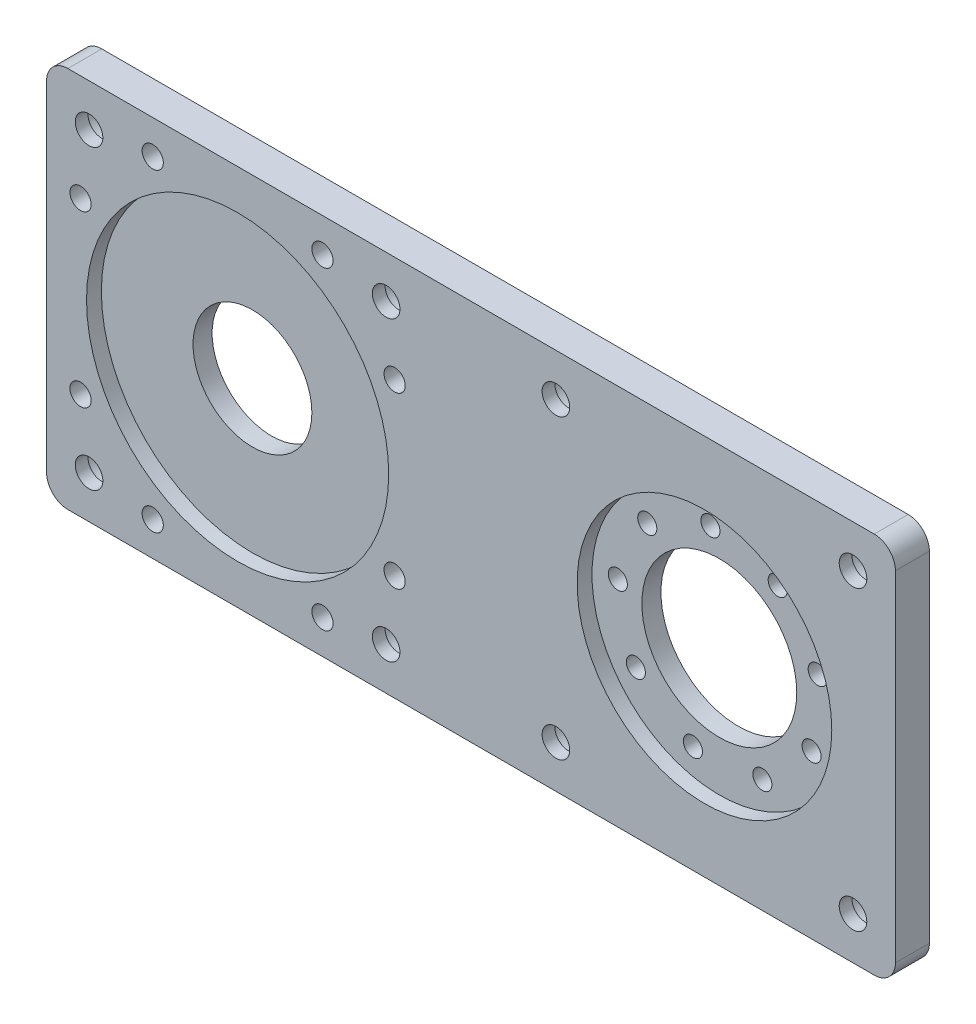
from build123d import *

# Parameters (mm, degrees)
SKETCH1_W           = 200
SKETCH1_H           = 90
SKETCH1_R           = 14
SKETCH1_R_2         = 18.25
SKETCH1_R_3         = 2.25
SKETCH1_R_4         = 3.25
SKETCH1_R_5         = 2.5
BOSS_EXTRUDE1_DEPTH = 4
FILLET1_R           = 5
SKETCH3_R           = 35.6
SKETCH3_R_2         = 30
CUT_EXTRUDE1_DEPTH  = 3.5
SKETCH4_R           = 5
CUT_EXTRUDE2_DEPTH  = 5


with BuildPart() as part:
    # Sketch1 → Boss-Extrude1 (new body, symmetric)
    with BuildSketch(Plane.XY):
        Rectangle(SKETCH1_W, SKETCH1_H)
        with Locations((-55, 0)):
            Circle(SKETCH1_R, mode=Mode.SUBTRACT)
        with Locations((55, 0)):
            Circle(SKETCH1_R_2, mode=Mode.SUBTRACT)
        with Locations((65.142838282, -21.751386889)):
            Circle(SKETCH1_R_3, mode=Mode.SUBTRACT)
        with Locations((48.788342918, -23.182219831)):
            Circle(SKETCH1_R_3, mode=Mode.SUBTRACT)
        with Locations((35.340350937, -13.765834472)):
            Circle(SKETCH1_R_3, mode=Mode.SUBTRACT)
        with Locations((31.091327246, 2.091737826)):
            Circle(SKETCH1_R_3, mode=Mode.SUBTRACT)
        with Locations((38.029437252, 16.970562748)):
            Circle(SKETCH1_R_3, mode=Mode.SUBTRACT)
        with Locations((52.908262174, 23.908672754)):
            Circle(SKETCH1_R_3, mode=Mode.SUBTRACT)
        with Locations((68.765834472, 19.659649063)):
            Circle(SKETCH1_R_3, mode=Mode.SUBTRACT)
        with Locations((78.182219831, 6.211657082)):
            Circle(SKETCH1_R_3, mode=Mode.SUBTRACT)
        with Locations((76.751386889, -10.142838282)):
            Circle(SKETCH1_R_3, mode=Mode.SUBTRACT)
        with Locations((-90, 35)):
            Circle(SKETCH1_R_4, mode=Mode.SUBTRACT)
        with Locations((-20, 35)):
            Circle(SKETCH1_R_4, mode=Mode.SUBTRACT)
        with Locations((-90, -35)):
            Circle(SKETCH1_R_4, mode=Mode.SUBTRACT)
        with Locations((-20, -35)):
            Circle(SKETCH1_R_4, mode=Mode.SUBTRACT)
        with Locations((90, 35)):
            Circle(SKETCH1_R_4, mode=Mode.SUBTRACT)
        with Locations((90, -35)):
            Circle(SKETCH1_R_4, mode=Mode.SUBTRACT)
        with Locations((20, -35)):
            Circle(SKETCH1_R_4, mode=Mode.SUBTRACT)
        with Locations((20, 35)):
            Circle(SKETCH1_R_4, mode=Mode.SUBTRACT)
        with Locations((-75, 37)):
            Circle(SKETCH1_R_5, mode=Mode.SUBTRACT)
        with Locations((-92, 20)):
            Circle(SKETCH1_R_5, mode=Mode.SUBTRACT)
        with Locations((-92, -20)):
            Circle(SKETCH1_R_5, mode=Mode.SUBTRACT)
        with Locations((-75, -37)):
            Circle(SKETCH1_R_5, mode=Mode.SUBTRACT)
        with Locations((-35, -37)):
            Circle(SKETCH1_R_5, mode=Mode.SUBTRACT)
        with Locations((-18, -20)):
            Circle(SKETCH1_R_5, mode=Mode.SUBTRACT)
        with Locations((-18, 20)):
            Circle(SKETCH1_R_5, mode=Mode.SUBTRACT)
        with Locations((-35, 37)):
            Circle(SKETCH1_R_5, mode=Mode.SUBTRACT)
    extrude(amount=BOSS_EXTRUDE1_DEPTH, both=True)

    # Fillet1
    fillet1_edges = [part.edges().sort_by_distance(p)[0] for p in [
        (100, -45, 0),
        (-100, -45, 0),
        (-100, 45, 0),
        (100, 45, 0),
    ]]
    fillet(fillet1_edges, radius=FILLET1_R)

    # Sketch3 → Cut-Extrude1 (cut)
    with BuildSketch(Plane.XY.offset(4)):
        with Locations((-55, 0)):
            Circle(SKETCH3_R)
        with Locations((55, 0)):
            Circle(SKETCH3_R_2)
    extrude(amount=-CUT_EXTRUDE1_DEPTH, mode=Mode.SUBTRACT)

    # Sketch4 → Cut-Extrude2 (cut)
    with BuildSketch(Plane(origin=(0, 0, -4), x_dir=(-1, 0, 0), z_dir=(0, 0, -1))):
        with Locations((90, 35)):
            Circle(SKETCH4_R)
        with Locations((20, 35)):
            Circle(SKETCH4_R)
        with Locations((90, -35)):
            Circle(SKETCH4_R)
        with Locations((20, -35)):
            Circle(SKETCH4_R)
        with Locations((-90, -35)):
            Circle(SKETCH4_R)
        with Locations((-20, -35)):
            Circle(SKETCH4_R)
        with Locations((-20, 35)):
            Circle(SKETCH4_R)
        with Locations((-90, 35)):
            Circle(SKETCH4_R)
    extrude(amount=-CUT_EXTRUDE2_DEPTH, mode=Mode.SUBTRACT)


solid = part.part
